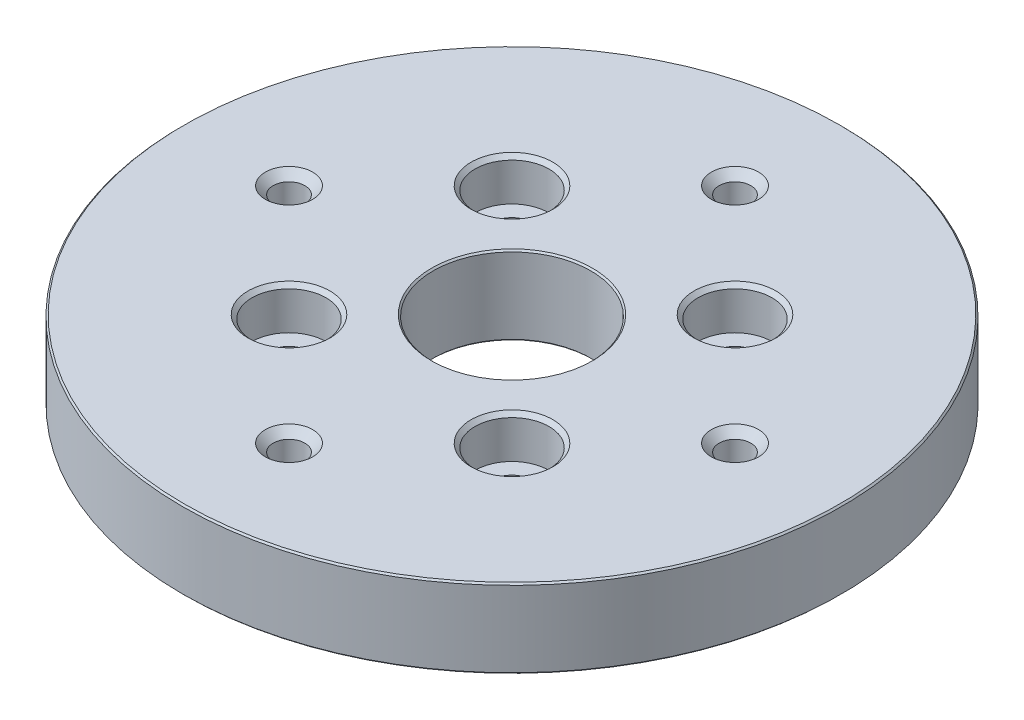
from build123d import *

# Parameters (mm, degrees)
SKETCH1_R                                     = 53.086
SKETCH1_R_2                                   = 12.7
BOSS_EXTRUDE1_DEPTH                           = 12.7
F_1_4_20_TAPPED_HOLE1_AT_2_COUNT              = 2
F_1_4_20_TAPPED_HOLE1_AT_2_PITCH              = 50.8
F_1_4_20_TAPPED_HOLE1_AT_3_COUNT              = 2
F_1_4_20_TAPPED_HOLE1_AT_3_PITCH              = 71.842048969
F_1_4_20_TAPPED_HOLE1_AT_4_COUNT              = 2
F_1_4_20_TAPPED_HOLE1_AT_4_PITCH              = 50.8
CBORE_FOR_1_4_BUTTON_HEAD_CAP_SCREW1_AT_COUNT = 2
CBORE_FOR_1_4_BUTTON_HEAD_CAP_SCREW1_AT_PITCH = 35.921024484
CBORE_FOR_1_4_BUTTON_HEAD_CAP_SCREW1_2_COUNT  = 2
CBORE_FOR_1_4_BUTTON_HEAD_CAP_SCREW1_2_PITCH  = 50.8
CBORE_FOR_1_4_BUTTON_HEAD_CAP_SCREW1_3_COUNT  = 2
CBORE_FOR_1_4_BUTTON_HEAD_CAP_SCREW1_3_PITCH  = 35.921024484
CHAMFER1_SIZE                                 = 0.254


with BuildPart() as part:
    # Sketch1 → Boss-Extrude1 (new body)
    with BuildSketch(Plane(origin=(0, 0, 0), x_dir=(1, 0, 0), z_dir=(0, 1, 0))):
        Circle(SKETCH1_R)
        Circle(SKETCH1_R_2, mode=Mode.SUBTRACT)
    extrude(amount=-BOSS_EXTRUDE1_DEPTH)

    # Sketch4 → 1/4-20 Tapped Hole1 (revolve, cut)
    with BuildSketch(Plane(origin=(0, 0, 35.921024484), x_dir=(0, 0, 1), z_dir=(1, 0, 0))):
        Polygon((0, 0), (0, 12.7), (3.81, 12.7), (2.5527, 11.4427), (2.5527, 1.2573), (3.81, 0), align=None)
    f_1_4_20_tapped_hole1 = revolve(axis=Axis((0, 6.35, 35.921024484), (0, -1, 0)), mode=Mode.SUBTRACT)

    # 1/4-20 Tapped Hole1 at 2: 1/4-20 Tapped Hole1 ×2
    with Locations(*[Vector(-0.707106781, 0, -0.707106781) * (i * F_1_4_20_TAPPED_HOLE1_AT_2_PITCH) for i in range(1, F_1_4_20_TAPPED_HOLE1_AT_2_COUNT)]):
        add(f_1_4_20_tapped_hole1, mode=Mode.SUBTRACT)

    # 1/4-20 Tapped Hole1 at 3: 1/4-20 Tapped Hole1 ×2
    with Locations(*[(0, 0, -i * F_1_4_20_TAPPED_HOLE1_AT_3_PITCH) for i in range(1, F_1_4_20_TAPPED_HOLE1_AT_3_COUNT)]):
        add(f_1_4_20_tapped_hole1, mode=Mode.SUBTRACT)

    # 1/4-20 Tapped Hole1 at 4: 1/4-20 Tapped Hole1 ×2
    with Locations(*[Vector(0.707106781, 0, -0.707106781) * (i * F_1_4_20_TAPPED_HOLE1_AT_4_PITCH) for i in range(1, F_1_4_20_TAPPED_HOLE1_AT_4_COUNT)]):
        add(f_1_4_20_tapped_hole1, mode=Mode.SUBTRACT)

    # Sketch5 → CBORE for 1/4 Button Head Cap Screw1 (revolve, cut)
    with BuildSketch(Plane(origin=(-17.960512242, 0, 17.960512242), x_dir=(0, 0, 1), z_dir=(1, 0, 0))):
        Polygon((0, 0), (0, 12.7), (3.8989, 12.7), (3.2639, 12.065), (3.2639, 6.7564), (5.95376, 6.7564), (5.95376, 0.635), (6.58876, 0), align=None)
    cbore_for_1_4_button_head_cap_screw1 = revolve(axis=Axis((-17.960512242, 6.35, 17.960512242), (0, -1, 0)), mode=Mode.SUBTRACT)

    # CBORE for 1/4 Button Head Cap Screw1 at: CBORE for 1/4 Button Head Cap Screw1 ×2
    with Locations(*[(0, 0, -i * CBORE_FOR_1_4_BUTTON_HEAD_CAP_SCREW1_AT_PITCH) for i in range(1, CBORE_FOR_1_4_BUTTON_HEAD_CAP_SCREW1_AT_COUNT)]):
        add(cbore_for_1_4_button_head_cap_screw1, mode=Mode.SUBTRACT)

    # CBORE for 1_4 Button Head Cap Screw1 2: CBORE for 1/4 Button Head Cap Screw1 ×2
    with Locations(*[Vector(0.707106781, 0, -0.707106781) * (i * CBORE_FOR_1_4_BUTTON_HEAD_CAP_SCREW1_2_PITCH) for i in range(1, CBORE_FOR_1_4_BUTTON_HEAD_CAP_SCREW1_2_COUNT)]):
        add(cbore_for_1_4_button_head_cap_screw1, mode=Mode.SUBTRACT)

    # CBORE for 1_4 Button Head Cap Screw1 3: CBORE for 1/4 Button Head Cap Screw1 ×2
    with Locations(*[(i * CBORE_FOR_1_4_BUTTON_HEAD_CAP_SCREW1_3_PITCH, 0, 0) for i in range(1, CBORE_FOR_1_4_BUTTON_HEAD_CAP_SCREW1_3_COUNT)]):
        add(cbore_for_1_4_button_head_cap_screw1, mode=Mode.SUBTRACT)

    # Chamfer1
    chamfer1_edges = [part.edges().sort_by_distance(p)[0] for p in [
        (-53.086, 0, 0),
        (-53.086, -12.7, 0),
        (-12.7, -12.7, 0),
        (-12.7, 0, 0),
    ]]
    chamfer(chamfer1_edges, length=CHAMFER1_SIZE)


solid = part.part
